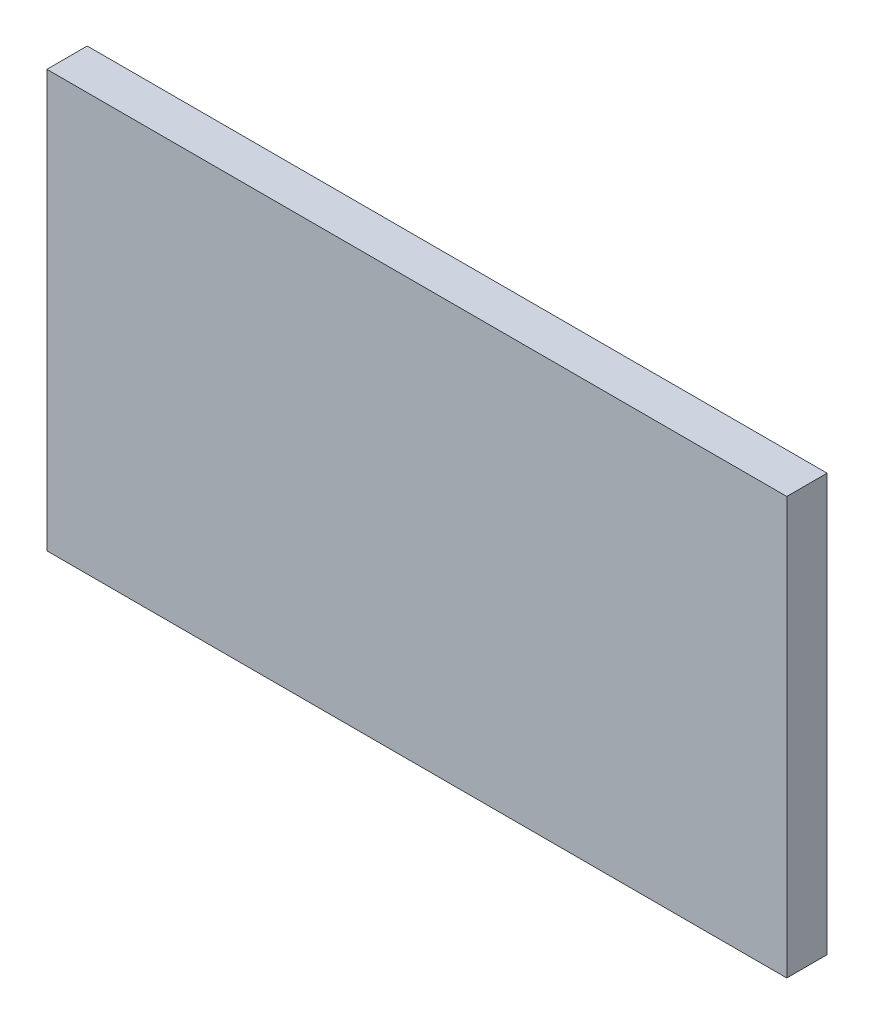
from build123d import *

# Parameters (mm, degrees)
SKETCH1_W           = 13.97
SKETCH1_H           = 7.874
BOSS_EXTRUDE1_DEPTH = 0.762


with BuildPart() as part:
    # Sketch1 → Boss-Extrude1 (new body)
    with BuildSketch(Plane.XY):
        with Locations((113.805407158, -88.362699103)):
            Rectangle(SKETCH1_W, SKETCH1_H)
    extrude(amount=BOSS_EXTRUDE1_DEPTH)


solid = part.part
